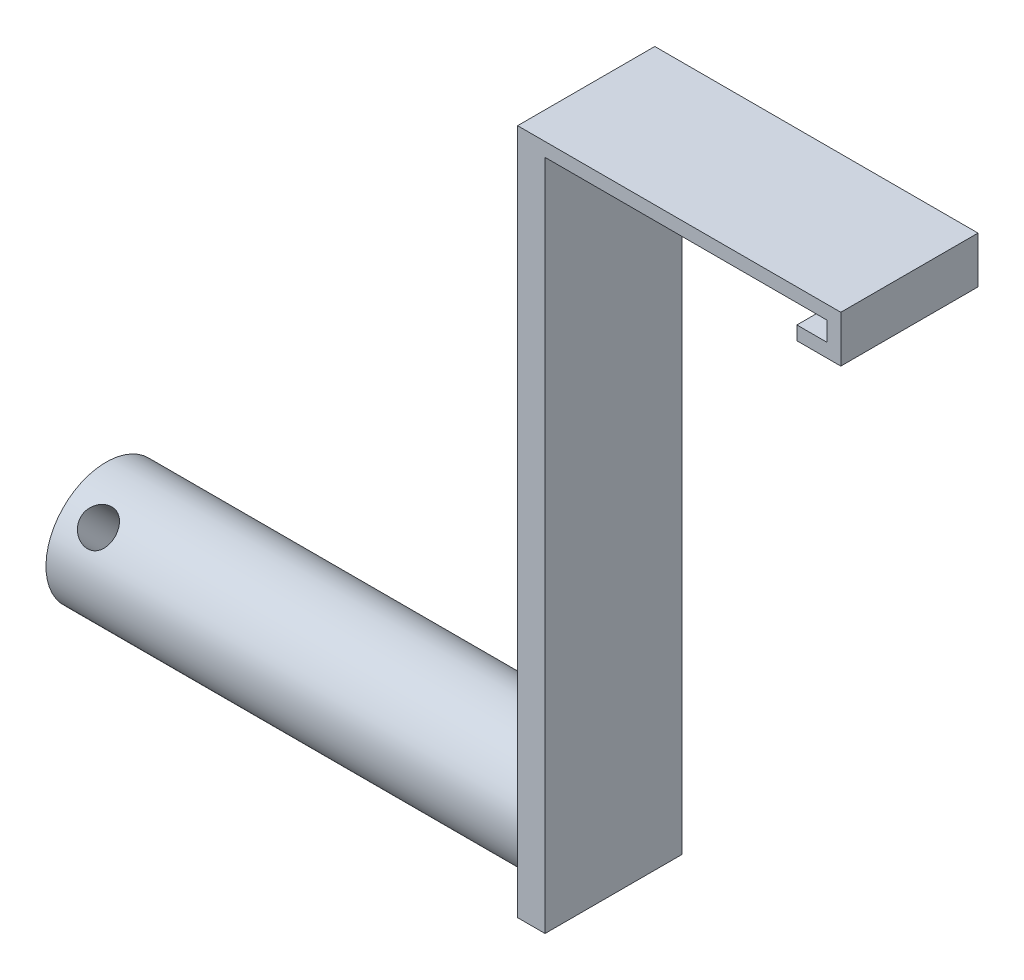
from build123d import *

# Parameters (mm, degrees)
BOSS_EXTRUDE1_DEPTH = 25.4
SKETCH2_R           = 11.1252
BOSS_EXTRUDE2_DEPTH = 88.9
SKETCH3_R           = 3.175
CUT_EXTRUDE1_DEPTH  = 28.972160483


with BuildPart() as part:
    # Sketch1 → Boss-Extrude1 (new body)
    with BuildSketch(Plane.XY):
        Polygon((0, 0), (5.588, 0), (5.588, 3.556), (-46.6344, 3.556), (-46.6344, -120.904), (-51.7144, -120.904), (-51.7144, 6.096), (8.128, 6.096), (8.128, -2.54), (0, -2.54), align=None)
    extrude(amount=BOSS_EXTRUDE1_DEPTH)

    # Sketch2 → Boss-Extrude2 (add)
    with BuildSketch(Plane.ZY.offset(51.7144)):
        with Locations((12.7, -109.7788)):
            Circle(SKETCH2_R)
    extrude(amount=BOSS_EXTRUDE2_DEPTH)

    # Sketch3 → Cut-Extrude1 (cut, through all)
    with BuildSketch(Plane(origin=(0, -40.672695638, -40.672695638), x_dir=(1, 0, 0), z_dir=(0, 0.707106781, 0.707106781))):
        with Locations((-134.2644, -86.605590032)):
            Circle(SKETCH3_R)
    extrude(amount=-CUT_EXTRUDE1_DEPTH, mode=Mode.SUBTRACT)


solid = part.part
